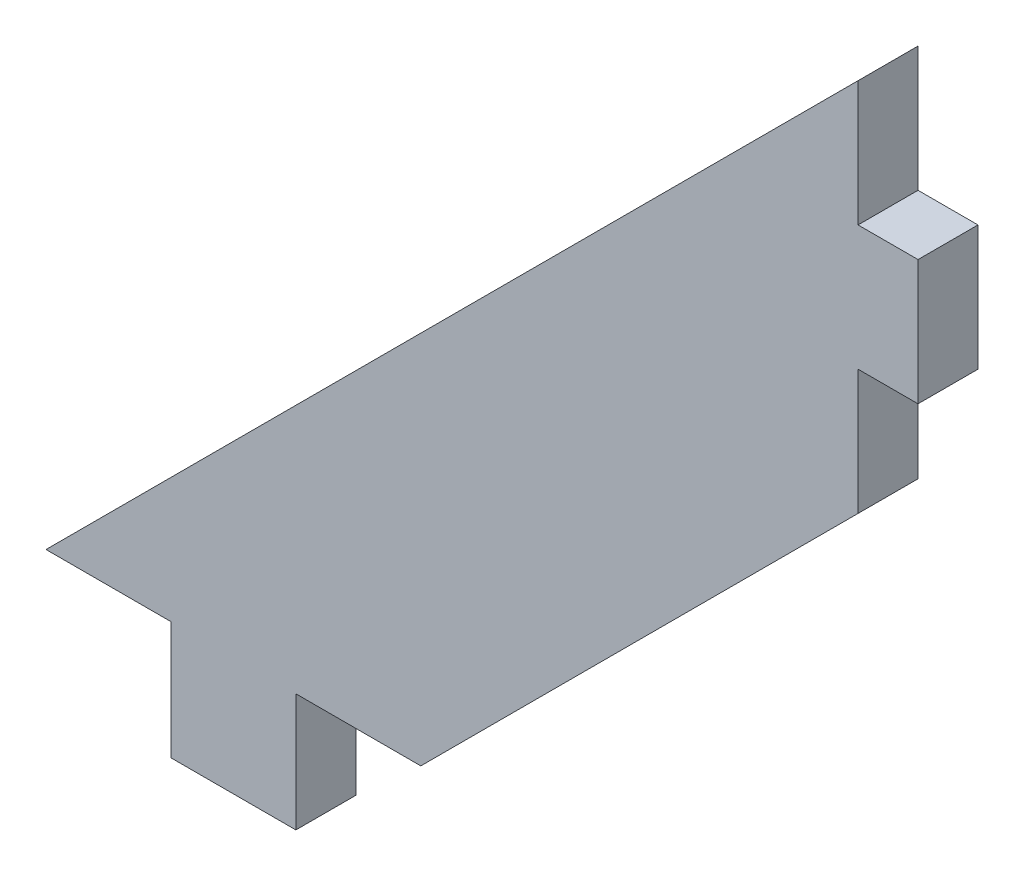
from build123d import *

# Parameters (mm, degrees)
BOSS_EXTRUDE1_DEPTH = 3.048


with BuildPart() as part:
    # Sketch1 → Boss-Extrude1 (new body)
    with BuildSketch(Plane.XY):
        Polygon((0, 0), (6.35, 0), (6.35, -5.9944), (12.7, -5.9944), (12.7, 0), (19.05, 0), (41.275, 22.225), (41.275, 28.575), (44.323, 28.575), (44.323, 34.925), (41.275, 34.925), (41.275, 41.275), align=None)
    extrude(amount=BOSS_EXTRUDE1_DEPTH)


solid = part.part
